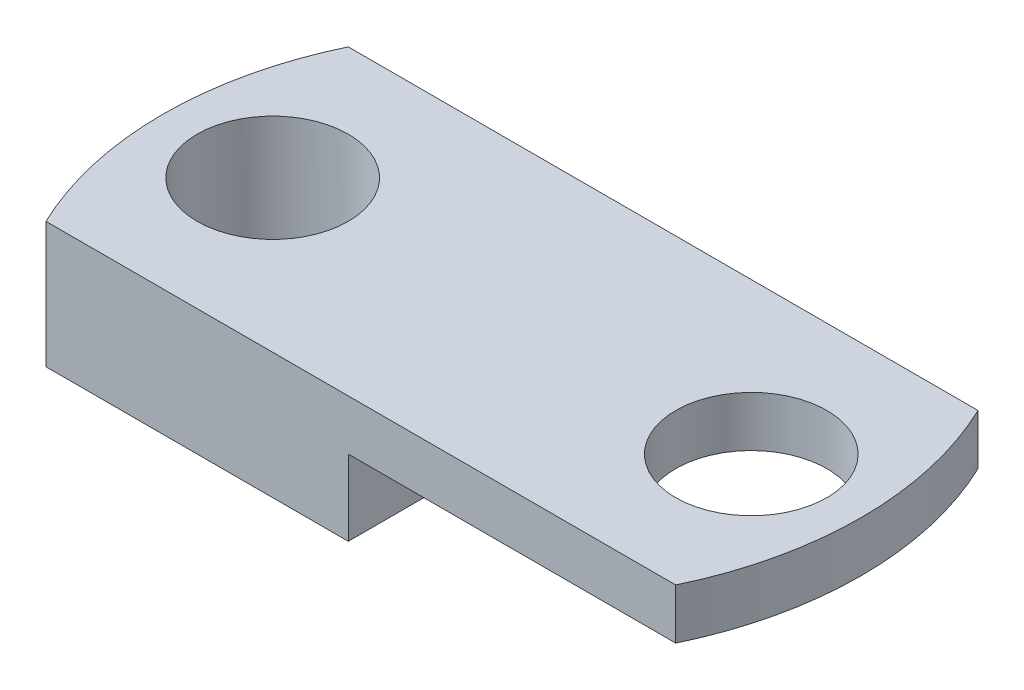
from build123d import *

# Parameters (mm, degrees)
BOSS_EXTRUDE2_DEPTH = 6.35
SKETCH4_R           = 3.81
CUT_EXTRUDE1_DEPTH  = 12.7
CUT_EXTRUDE2_DEPTH  = 3.81


with BuildPart() as part:
    # Sketch3 → Boss-Extrude2 (new body)
    with BuildSketch(Plane(origin=(0, 0, 0), x_dir=(1, 0, 0), z_dir=(0, 1, 0))):
        with BuildLine():
            Line((-15.875, 7.62), (15.875, 7.62))
            ThreePointArc((15.875, 7.62), (17.609089272, 0), (15.875, -7.62))
            Line((15.875, -7.62), (-15.875, -7.62))
            ThreePointArc((-15.875, -7.62), (-17.609089272, 0), (-15.875, 7.62))
        make_face()
    extrude(amount=BOSS_EXTRUDE2_DEPTH)

    # Sketch4 → Cut-Extrude1 (cut)
    with BuildSketch(Plane(origin=(0, 6.35, 0), x_dir=(1, 0, 0), z_dir=(0, 1, 0))):
        with Locations((12.065, 0)):
            Circle(SKETCH4_R)
        with Locations((-12.065, 0)):
            Circle(SKETCH4_R)
    extrude(amount=-CUT_EXTRUDE1_DEPTH, mode=Mode.SUBTRACT)

    # Sketch5 → Cut-Extrude2 (cut)
    with BuildSketch(Plane.XZ):
        with BuildLine():
            Line((15.875, 7.62), (-0.635, 7.62))
            Line((-0.635, 7.62), (-0.635, -7.62))
            Line((-0.635, -7.62), (15.875, -7.62))
            ThreePointArc((15.875, -7.62), (17.609089272, 0), (15.875, 7.62))
        make_face()
    extrude(amount=-CUT_EXTRUDE2_DEPTH, mode=Mode.SUBTRACT)


solid = part.part
